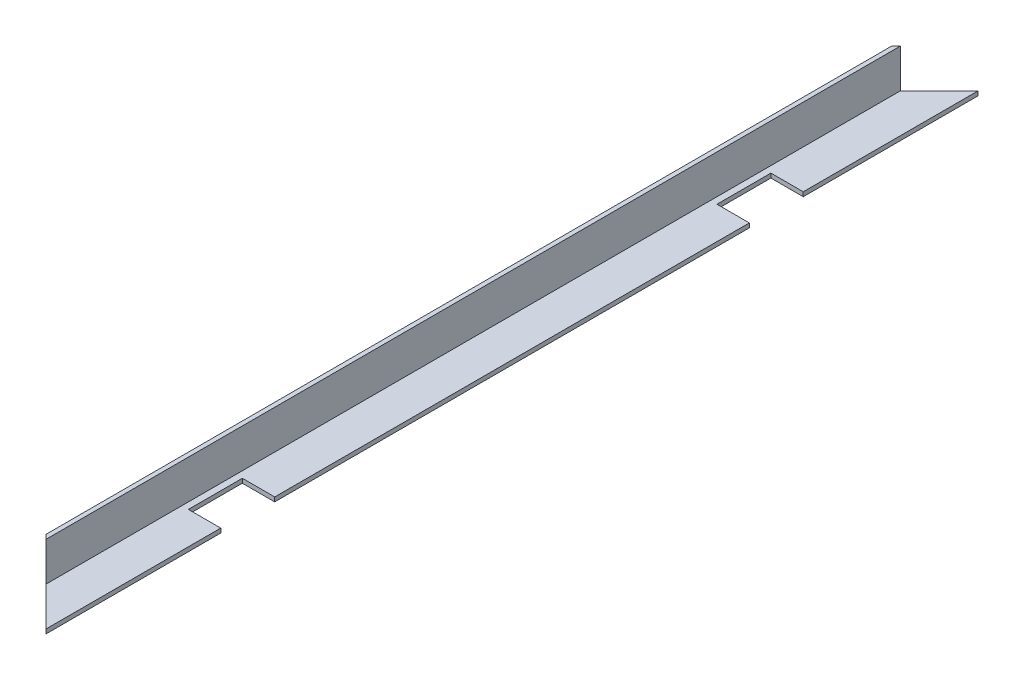
from build123d import *

# Parameters (mm, degrees)
BOSS_EXTRUDE1_DEPTH = 432
CUT_EXTRUDE1_DEPTH  = 23
SKETCH3_W           = 15
SKETCH3_H           = 25
CUT_EXTRUDE2_DEPTH  = 3


with BuildPart() as part:
    # Sketch1 → Boss-Extrude1 (new body)
    with BuildSketch(Plane.XY):
        Polygon((0, 0), (20, 0), (20, 2), (2, 2), (2, 20), (0, 20), align=None)
    extrude(amount=BOSS_EXTRUDE1_DEPTH)

    # Sketch2 → Cut-Extrude1 (cut, symmetric)
    with BuildSketch(Plane(origin=(0, 2, 0), x_dir=(1, 0, 0), z_dir=(0, 1, 0))):
        Polygon((0, -432), (20, -432), (0, -412), align=None)
        Polygon((20, 0), (0, -20), (0, 0), align=None)
    extrude(amount=CUT_EXTRUDE1_DEPTH, both=True, mode=Mode.SUBTRACT)

    # Sketch3 → Cut-Extrude2 (cut, through all)
    with BuildSketch(Plane(origin=(0, 2, 0), x_dir=(1, 0, 0), z_dir=(0, 1, 0))):
        with Locations((12.5, -93.5)):
            Rectangle(SKETCH3_W, SKETCH3_H)
        with Locations((12.5, -338.5)):
            Rectangle(SKETCH3_W, SKETCH3_H)
    extrude(amount=-CUT_EXTRUDE2_DEPTH, mode=Mode.SUBTRACT)


solid = part.part
